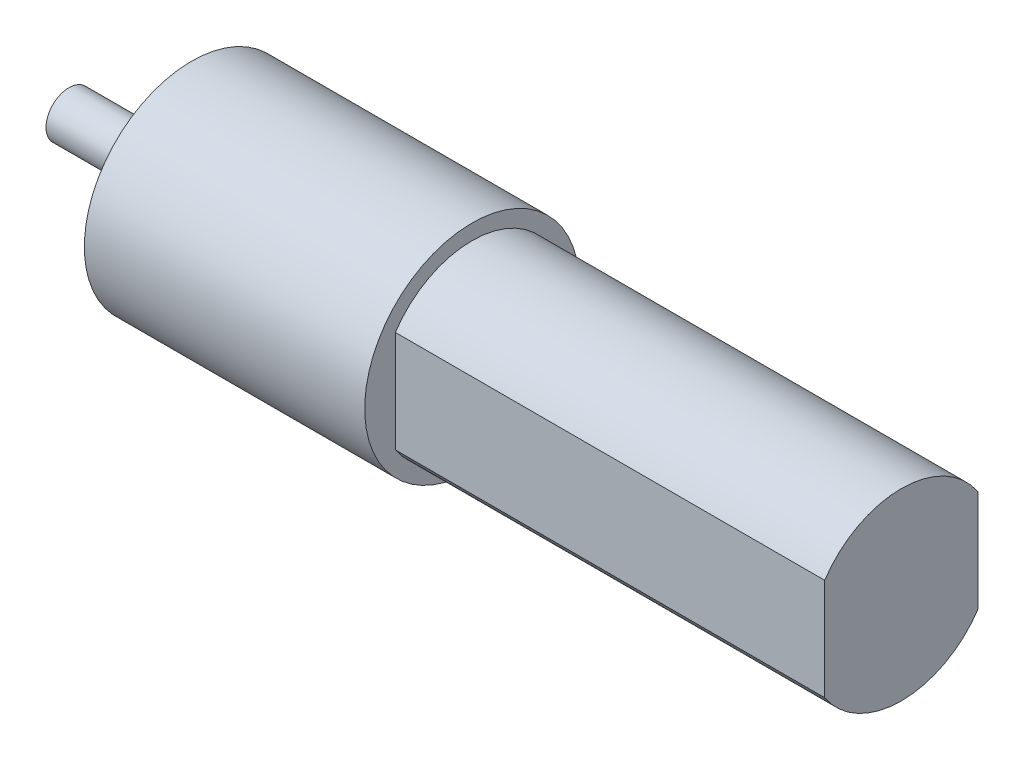
from build123d import *

# Parameters (mm, degrees)
SKETCH1_R           = 11.1125
BOSS_EXTRUDE1_DEPTH = 29.028571429
SKETCH2_R           = 9.525
BOSS_EXTRUDE2_DEPTH = 44.45
SKETCH3_W           = 2.553411187
SKETCH3_H           = 10.53028371
SKETCH3_W_2         = 2.754606744
CUT_EXTRUDE1_DEPTH  = 44.45
SKETCH4_R           = 6.35
BOSS_EXTRUDE3_DEPTH = 1.5875
SKETCH5_W           = 1.859243387
SKETCH5_H           = 6.148361062
SKETCH5_W_2         = 2.232892279
CUT_EXTRUDE2_DEPTH  = 1.5875
SKETCH6_R           = 2.38125
BOSS_EXTRUDE4_DEPTH = 11.1125


with BuildPart() as part:
    # Sketch1 → Boss-Extrude1 (new body)
    with BuildSketch(Plane(origin=(0, 0, 0), x_dir=(0, 0, -1), z_dir=(1, 0, 0))):
        Circle(SKETCH1_R)
    extrude(amount=BOSS_EXTRUDE1_DEPTH)

    # Sketch2 → Boss-Extrude2 (add)
    with BuildSketch(Plane(origin=(29.028571429, 0, 0), x_dir=(0, 0, -1), z_dir=(1, 0, 0))):
        Circle(SKETCH2_R)
    extrude(amount=BOSS_EXTRUDE2_DEPTH)

    # Sketch3 → Cut-Extrude1 (cut)
    with BuildSketch(Plane(origin=(73.478571429, 0, 0), x_dir=(0, 0, -1), z_dir=(1, 0, 0))):
        with Locations((-9.214205594, 0)):
            Rectangle(SKETCH3_W, SKETCH3_H)
        with Locations((9.314803372, 0)):
            Rectangle(SKETCH3_W_2, SKETCH3_H)
    extrude(amount=-CUT_EXTRUDE1_DEPTH, mode=Mode.SUBTRACT)

    # Sketch4 → Boss-Extrude3 (add)
    with BuildSketch(Plane.ZY):
        Circle(SKETCH4_R)
    extrude(amount=BOSS_EXTRUDE3_DEPTH)

    # Sketch5 → Cut-Extrude2 (cut)
    with BuildSketch(Plane.ZY.offset(1.5875)):
        with Locations((-6.485871694, 0)):
            Rectangle(SKETCH5_W, SKETCH5_H)
        with Locations((6.67269614, 0)):
            Rectangle(SKETCH5_W_2, SKETCH5_H)
    extrude(amount=-CUT_EXTRUDE2_DEPTH, mode=Mode.SUBTRACT)

    # Sketch6 → Boss-Extrude4 (add)
    with BuildSketch(Plane.ZY.offset(1.5875)):
        Circle(SKETCH6_R)
    extrude(amount=BOSS_EXTRUDE4_DEPTH)


solid = part.part
